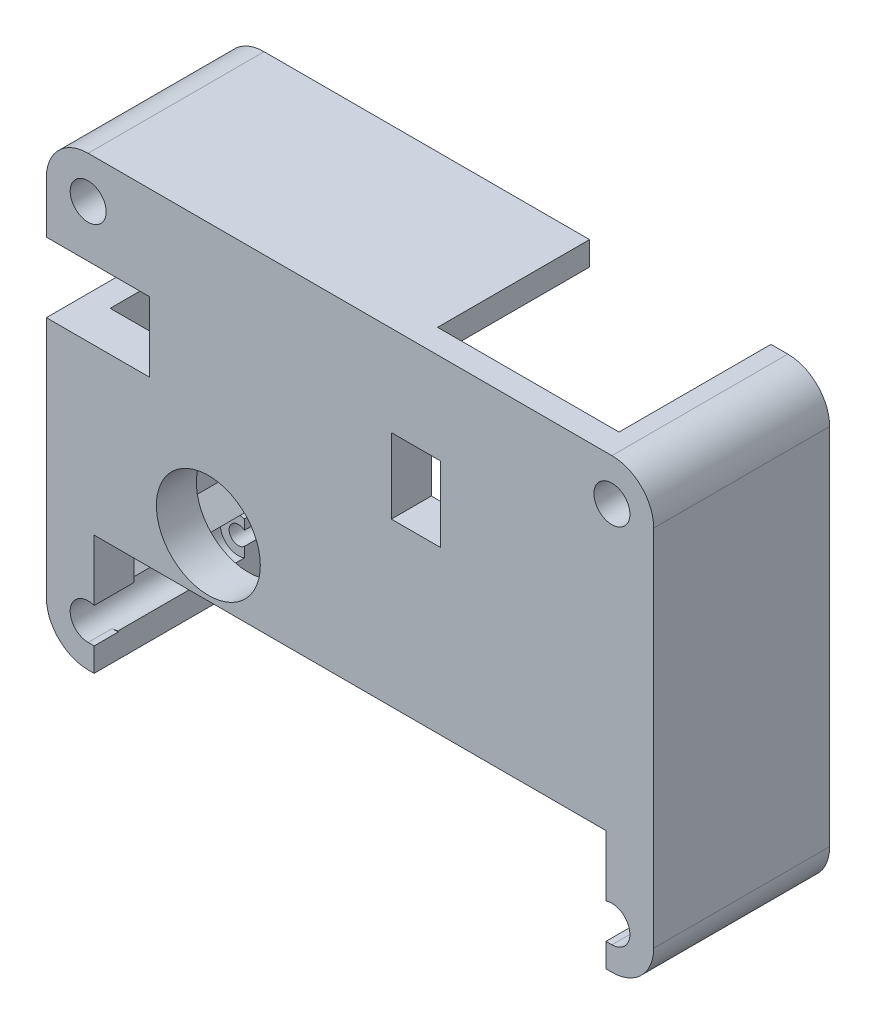
from build123d import *

# Parameters (mm, degrees)
SKETCH1_R                       = 1.15
BOSS_EXTRUDE4_DEPTH             = 3.22
BOSS_EXTRUDE5_DEPTH             = 19
BOSS_EXTRUDE6_DEPTH             = 19
SKETCH3_W                       = 19
SKETCH3_H                       = 8.72
CUT_EXTRUDE1_DEPTH              = 93.159937036
SKETCH2_5_R                     = 6.5
SKETCH2_5_R_2                   = 2.25
SKETCH2_5_W                     = 6.12
SKETCH2_5_H                     = 9.37
BOSS_EXTRUDE9_DEPTH             = 3
BOSS_EXTRUDE9_DEPTH_BACK        = 2
CUT_EXTRUDE8_REACH              = 94.16
SKETCH2_6_W                     = 64
SKETCH2_6_H                     = 14.977988196
CUT_EXTRUDE8_DIRECTION_2_REACH  = 94.16
CUT_EXTRUDE10_REACH             = 94.825
SKETCH4_W                       = 22.69
SKETCH4_H                       = 19
CUT_EXTRUDE10_DIRECTION_2_DEPTH = 3
CUT_EXTRUDE11_REACH             = 93.768
SKETCH5_W                       = 12.894145303
SKETCH5_H                       = 8.72


with BuildPart() as part:
    # Sketch1 → Boss-Extrude4 (new body)
    with BuildSketch(Plane.XY):
        with BuildLine():
            ThreePointArc((2.480923897, -4.488118441), (3.840990258, -3.840990258), (4.488118441, -2.480923897))
            Line((4.488118441, -2.480923897), (2.480923897, -4.488118441))
        make_face()
        with BuildLine():
            Line((2.480923897, -4.488118441), (4.488118441, -2.480923897))
            ThreePointArc((4.488118441, -2.480923897), (4.497027647, -2.365614681), (4.5, -2.25))
            ThreePointArc((4.5, -2.25), (0.579359589, -0.742863438), (2.480923897, -4.488118441))
        make_face()
        with Locations(Location((2.25, -2.25, 0), (0, 0, 180))):
            Circle(SKETCH1_R, mode=Mode.SUBTRACT)
        with BuildLine():
            ThreePointArc((4.5, -47.75), (4.497027647, -47.634385319), (4.488118441, -47.519076103))
            Line((4.488118441, -47.519076103), (2.480923897, -45.511881559))
            ThreePointArc((2.480923897, -45.511881559), (0.579359589, -49.257136562), (4.5, -47.75))
        make_face()
        with Locations(Location((2.25, -47.75, 0), (0, 0, 180))):
            Circle(SKETCH1_R, mode=Mode.SUBTRACT)
        with BuildLine():
            Line((2.480923897, -45.511881559), (4.488118441, -47.519076103))
            ThreePointArc((4.488118441, -47.519076103), (3.840990258, -46.159009742), (2.480923897, -45.511881559))
        make_face()
        with BuildLine():
            Line((67.519076103, -45.511881559), (65.511881559, -47.519076103))
            ThreePointArc((65.511881559, -47.519076103), (67.634385319, -49.997027647), (70, -47.75))
            ThreePointArc((70, -47.75), (69.257136562, -46.079359589), (67.519076103, -45.511881559))
        make_face()
        with Locations(Location((67.75, -47.75, 0), (0, 0, 180))):
            Circle(SKETCH1_R, mode=Mode.SUBTRACT)
        with BuildLine():
            ThreePointArc((67.519076103, -45.511881559), (66.159009742, -46.159009742), (65.511881559, -47.519076103))
            Line((65.511881559, -47.519076103), (67.519076103, -45.511881559))
        make_face()
        with BuildLine():
            ThreePointArc((70, -2.25), (67.634385319, -0.002972353), (65.511881559, -2.480923897))
            Line((65.511881559, -2.480923897), (67.519076103, -4.488118441))
            ThreePointArc((67.519076103, -4.488118441), (69.257136562, -3.920640411), (70, -2.25))
        make_face()
        with Locations(Location((67.75, -2.25, 0), (0, 0, 180))):
            Circle(SKETCH1_R, mode=Mode.SUBTRACT)
        with BuildLine():
            Line((67.519076103, -4.488118441), (65.511881559, -2.480923897))
            ThreePointArc((65.511881559, -2.480923897), (66.159009742, -3.840990258), (67.519076103, -4.488118441))
        make_face()
    extrude(amount=BOSS_EXTRUDE4_DEPTH)

    # Sketch1_6 → Boss-Extrude5 (add)
    with BuildSketch(Plane.XY):
        with BuildLine():
            Line((65.511881559, -47.519076103), (63.030957663, -50))
            ThreePointArc((63.030957663, -50), (71.446745906, -51.446745906), (70, -43.030957663))
            Line((70, -43.030957663), (67.519076103, -45.511881559))
            ThreePointArc((67.519076103, -45.511881559), (69.340990258, -49.340990258), (65.511881559, -47.519076103))
        make_face()
        with BuildLine():
            ThreePointArc((70, -6.969042337), (71.446745906, 1.446745906), (63.030957663, 0))
            Line((63.030957663, 0), (65.511881559, -2.480923897))
            ThreePointArc((65.511881559, -2.480923897), (69.340990258, -0.659009742), (67.519076103, -4.488118441))
            Line((67.519076103, -4.488118441), (70, -6.969042337))
        make_face()
        with BuildLine():
            Line((4.488118441, -2.480923897), (6.969042337, 0))
            ThreePointArc((6.969042337, 0), (-1.446745906, 1.446745906), (0, -6.969042337))
            Line((0, -6.969042337), (2.480923897, -4.488118441))
            ThreePointArc((2.480923897, -4.488118441), (0.659009742, -0.659009742), (4.488118441, -2.480923897))
        make_face()
        with BuildLine():
            ThreePointArc((0, -43.030957663), (-1.446745906, -51.446745906), (6.969042337, -50))
            Line((6.969042337, -50), (4.488118441, -47.519076103))
            ThreePointArc((4.488118441, -47.519076103), (0.659009742, -49.340990258), (2.480923897, -45.511881559))
            Line((2.480923897, -45.511881559), (0, -43.030957663))
        make_face()
    extrude(amount=BOSS_EXTRUDE5_DEPTH)

    # Sketch2 → Boss-Extrude6 (add)
    with BuildSketch(Plane.XY.offset(19)):
        with BuildLine():
            Line((0, -43.030957663), (0, -6.969042337))
            ThreePointArc((0, -6.969042337), (-2.171246093, -5.040061571), (-2.977988196, -2.25))
            Line((-2.977988196, -2.25), (-2.977988196, -47.75))
            ThreePointArc((-2.977988196, -47.75), (-2.171246093, -44.959938429), (0, -43.030957663))
        make_face()
        with BuildLine():
            Line((67.75, 2.977988196), (2.25, 2.977988196))
            ThreePointArc((2.25, 2.977988196), (5.040061571, 2.171246093), (6.969042337, 0))
            Line((6.969042337, 0), (63.030957663, 0))
            ThreePointArc((63.030957663, 0), (64.959938429, 2.171246093), (67.75, 2.977988196))
        make_face()
        with BuildLine():
            Line((2.25, -52.977988196), (67.75, -52.977988196))
            ThreePointArc((67.75, -52.977988196), (64.959938429, -52.171246093), (63.030957663, -50))
            Line((63.030957663, -50), (6.969042337, -50))
            ThreePointArc((6.969042337, -50), (5.040061571, -52.171246093), (2.25, -52.977988196))
        make_face()
        with BuildLine():
            Line((72.977988196, -47.75), (72.977988196, -2.25))
            ThreePointArc((72.977988196, -2.25), (72.171246093, -5.040061571), (70, -6.969042337))
            Line((70, -6.969042337), (70, -43.030957663))
            ThreePointArc((70, -43.030957663), (72.171246093, -44.959938429), (72.977988196, -47.75))
        make_face()
    extrude(amount=-BOSS_EXTRUDE6_DEPTH)

    # Sketch3 → Cut-Extrude1 (cut, through all)
    with BuildSketch(Plane(origin=(0, 0, 0), x_dir=(0, 0, -1), z_dir=(1, 0, 0))):
        with Locations((-9.5, -13.08)):
            Rectangle(SKETCH3_W, SKETCH3_H)
    extrude(amount=-CUT_EXTRUDE1_DEPTH, mode=Mode.SUBTRACT)

    # Sketch2_5 → Boss-Extrude9 (add, two sides)
    with BuildSketch(Plane.XY.offset(19)) as boss_extrude9_sk:
        with BuildLine():
            Line((2.25, -52.977988196), (67.75, -52.977988196))
            ThreePointArc((67.75, -52.977988196), (71.446745906, -51.446745906), (72.977988196, -47.75))
            Line((72.977988196, -47.75), (72.977988196, -2.25))
            ThreePointArc((72.977988196, -2.25), (71.446745906, 1.446745906), (67.75, 2.977988196))
            Line((67.75, 2.977988196), (2.25, 2.977988196))
            ThreePointArc((2.25, 2.977988196), (-1.446745906, 1.446745906), (-2.977988196, -2.25))
            Line((-2.977988196, -2.25), (-2.977988196, -47.75))
            ThreePointArc((-2.977988196, -47.75), (-1.446745906, -51.446745906), (2.25, -52.977988196))
        make_face()
        with BuildLine():
            Line((3, -50), (2.25, -50))
            ThreePointArc((2.25, -50), (0.032403241, -47.369520548), (3, -45.628679656))
            Line((3, -45.628679656), (3, -50))
        make_face(mode=Mode.SUBTRACT)
        with Locations((17.28, -30.89)):
            Circle(SKETCH2_5_R, mode=Mode.SUBTRACT)
        with BuildLine():
            ThreePointArc((67, -45.628679656), (69.967596759, -47.369520548), (67.75, -50))
            Line((67.75, -50), (67, -50))
            Line((67, -50), (67, -45.628679656))
        make_face(mode=Mode.SUBTRACT)
        with Locations(Location((2.25, -2.25, 0), (0, 0, 275.890801568))):
            Circle(SKETCH2_5_R_2, mode=Mode.SUBTRACT)
        with Locations((43.23, -13)):
            Rectangle(SKETCH2_5_W, SKETCH2_5_H, mode=Mode.SUBTRACT)
        with Locations(Location((67.75, -2.25, 0), (0, 0, 185.890801568))):
            Circle(SKETCH2_5_R_2, mode=Mode.SUBTRACT)
    extrude(amount=BOSS_EXTRUDE9_DEPTH)
    extrude(boss_extrude9_sk.sketch, amount=-BOSS_EXTRUDE9_DEPTH_BACK)

    # Sketch2_6 → Cut-Extrude8 (cut, up to next)
    with BuildSketch(Plane.XY.offset(19), mode=Mode.PRIVATE) as cut_extrude8_sk1:
        with Locations((35, -45.488994098)):
            Rectangle(SKETCH2_6_W, SKETCH2_6_H)
    cut_extrude8_tool1 = extrude(cut_extrude8_sk1.sketch, amount=-CUT_EXTRUDE8_REACH, mode=Mode.PRIVATE) & part.part
    add(cut_extrude8_tool1.solids().sort_by_distance((35, -45.488994, 19))[0], mode=Mode.SUBTRACT)

    # Sketch2_6 → Cut-Extrude8 direction 2 (cut, up to next)
    with BuildSketch(Plane.XY.offset(19), mode=Mode.PRIVATE) as cut_extrude8_direction_2_sk1:
        with Locations((35, -45.488994098)):
            Rectangle(SKETCH2_6_W, SKETCH2_6_H)
    cut_extrude8_direction_2_tool1 = extrude(cut_extrude8_direction_2_sk1.sketch, amount=CUT_EXTRUDE8_DIRECTION_2_REACH, mode=Mode.PRIVATE) & part.part
    add(cut_extrude8_direction_2_tool1.solids().sort_by_distance((35, -45.488994, 19))[0], mode=Mode.SUBTRACT)

    # Sketch4 → Cut-Extrude10 (cut, up to next)
    with BuildSketch(Plane.XZ, mode=Mode.PRIVATE) as cut_extrude10_sk1:
        with Locations((54.295, 9.5)):
            Rectangle(SKETCH4_W, SKETCH4_H)
    cut_extrude10_tool1 = extrude(cut_extrude10_sk1.sketch, amount=-CUT_EXTRUDE10_REACH, mode=Mode.PRIVATE) & part.part
    add(cut_extrude10_tool1.solids().sort_by_distance((54.295, 0, 9.5))[0], mode=Mode.SUBTRACT)

    # Sketch4 → Cut-Extrude10 direction 2 (cut)
    with BuildSketch(Plane.XZ):
        with Locations((54.295, 9.5)):
            Rectangle(SKETCH4_W, SKETCH4_H)
    extrude(amount=CUT_EXTRUDE10_DIRECTION_2_DEPTH, mode=Mode.SUBTRACT)

    # Sketch5 → Cut-Extrude11 (cut, up to next)
    with BuildSketch(Plane(origin=(0, 0, 17), x_dir=(-1, 0, 0), z_dir=(0, 0, -1)), mode=Mode.PRIVATE) as cut_extrude11_sk1:
        with Locations((-3.469084455, -13.08)):
            Rectangle(SKETCH5_W, SKETCH5_H)
    cut_extrude11_tool1 = extrude(cut_extrude11_sk1.sketch, amount=-CUT_EXTRUDE11_REACH, mode=Mode.PRIVATE) & part.part
    add(cut_extrude11_tool1.solids().sort_by_distance((3.469084, -13.08, 17))[0], mode=Mode.SUBTRACT)


solid = part.part
